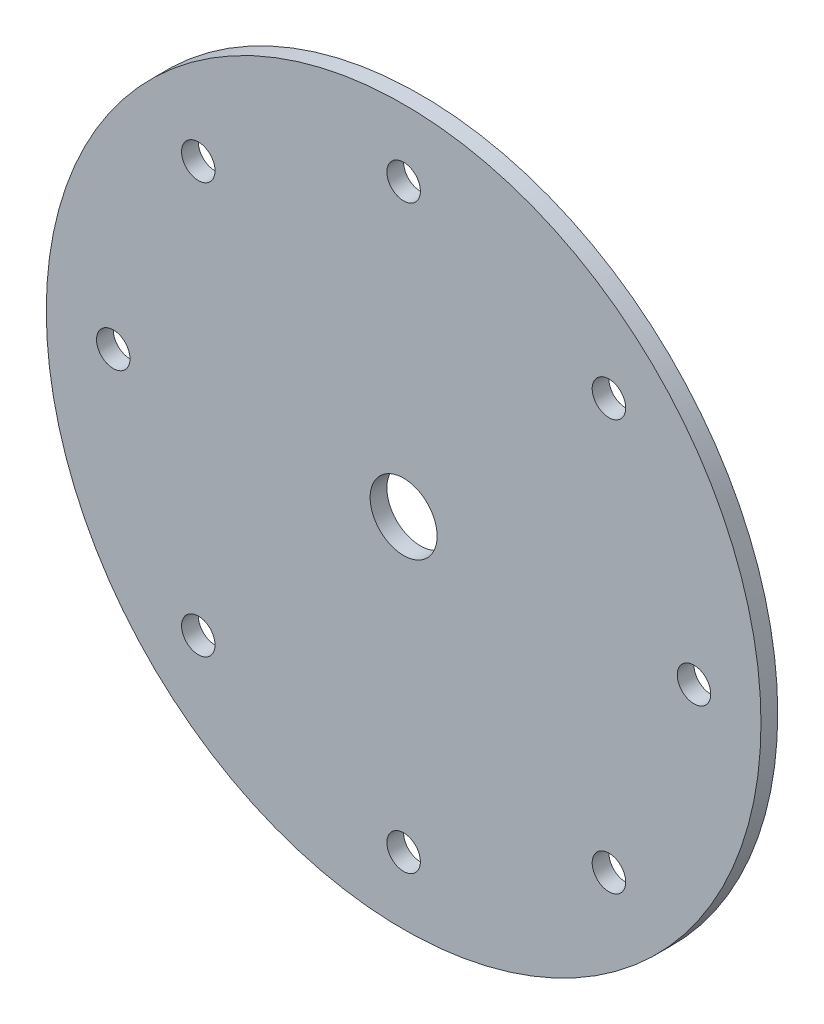
from build123d import *

# Parameters (mm, degrees)
SKETCH1_R        = 101.6
SKETCH1_R_2      = 9.525
SKETCH1_R_3      = 4.7625
ROTOR_DISC_DEPTH = 4.7625


with BuildPart() as part:
    # Sketch1 → Rotor Disc (new body)
    with BuildSketch(Plane.XY):
        Circle(SKETCH1_R)
        Circle(SKETCH1_R_2, mode=Mode.SUBTRACT)
        with Locations((0, 82.55)):
            Circle(SKETCH1_R_3, mode=Mode.SUBTRACT)
        with Locations((58.371664787, 58.371664787)):
            Circle(SKETCH1_R_3, mode=Mode.SUBTRACT)
        with Locations((82.55, 0)):
            Circle(SKETCH1_R_3, mode=Mode.SUBTRACT)
        with Locations((58.371664787, -58.371664787)):
            Circle(SKETCH1_R_3, mode=Mode.SUBTRACT)
        with Locations((0, -82.55)):
            Circle(SKETCH1_R_3, mode=Mode.SUBTRACT)
        with Locations((-58.371664787, -58.371664787)):
            Circle(SKETCH1_R_3, mode=Mode.SUBTRACT)
        with Locations((-82.55, 0)):
            Circle(SKETCH1_R_3, mode=Mode.SUBTRACT)
        with Locations((-58.371664787, 58.371664787)):
            Circle(SKETCH1_R_3, mode=Mode.SUBTRACT)
    extrude(amount=ROTOR_DISC_DEPTH)


solid = part.part
